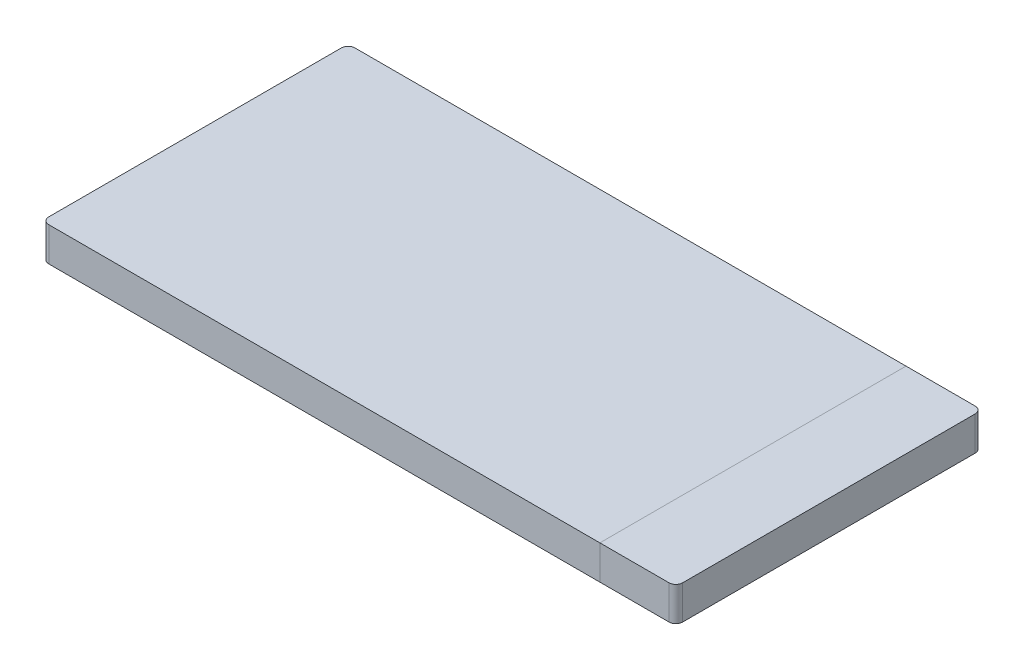
from build123d import *

# Parameters (mm, degrees)
SKETCH_1_W      = 24.6
SKETCH_1_H      = 13.5
EXTRUDE_1_DEPTH = 1.5
SKETCH_1_3_W    = 3.35
SKETCH_1_3_H    = 13.5
EXTRUDE_2_DEPTH = 1.5
FILLET_1_R      = 0.3
FILLET_2_R      = 0.3


with BuildPart() as part:
    # 草图1 → 凸台-拉伸1 (new body)
    with BuildSketch(Plane(origin=(0, 0, 0), x_dir=(1, 0, 0), z_dir=(0, 1, 0))):
        with Locations((-1.675, 0)):
            Rectangle(SKETCH_1_W, SKETCH_1_H)
    extrude(amount=EXTRUDE_1_DEPTH)

    # 圆角2
    fillet_2_edges = [part.edges().sort_by_distance(p)[0] for p in [
        (-13.975, 0.75, -6.75),
        (-13.975, 0.75, 6.75),
    ]]
    fillet(fillet_2_edges, radius=FILLET_2_R)


with BuildPart() as body_2:
    # 草图1<3> → 凸台-拉伸2 (new body)
    with BuildSketch(Plane(origin=(0, 0, 0), x_dir=(1, 0, 0), z_dir=(0, 1, 0))):
        with Locations((12.3, 0)):
            Rectangle(SKETCH_1_3_W, SKETCH_1_3_H)
    extrude(amount=EXTRUDE_2_DEPTH)

    # 圆角1
    fillet_1_edges = [body_2.edges().sort_by_distance(p)[0] for p in [
        (13.975, 0.75, -6.75),
        (13.975, 0.75, 6.75),
    ]]
    fillet(fillet_1_edges, radius=FILLET_1_R)


solid = Compound([part.part, body_2.part])
